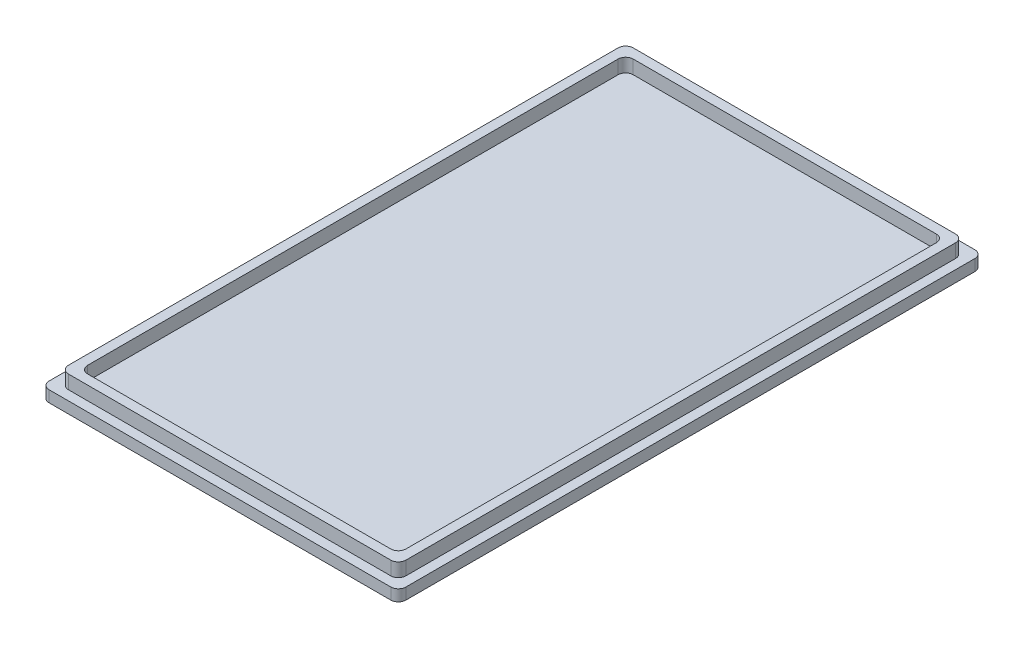
from build123d import *

# Parameters (mm, degrees)
SKETCH1_W           = 47.09116882
SKETCH1_H           = 77.09116882
BOSS_EXTRUDE1_DEPTH = 1.5
SKETCH2_W           = 44.545584412
SKETCH2_H           = 74.545584412
SKETCH2_W_2         = 42
SKETCH2_H_2         = 72
BOSS_EXTRUDE2_DEPTH = 1.8
FILLET1_R           = 1
SKETCH3_W           = 24
SKETCH3_H           = 64
BOSS_EXTRUDE3_DEPTH = 10
SKETCH4_W           = 48
SKETCH4_H           = 6
CUT_EXTRUDE1_DEPTH  = 24
FILLET2_R           = 6
FILLET3_R           = 1


with BuildPart() as part:
    # Sketch1 → Boss-Extrude1 (new body)
    with BuildSketch(Plane(origin=(0, 0, 0), x_dir=(1, 0, 0), z_dir=(0, 1, 0))):
        with Locations((23.54558441, -38.54558441)):
            Rectangle(SKETCH1_W, SKETCH1_H)
    extrude(amount=BOSS_EXTRUDE1_DEPTH)

    # Sketch2 → Boss-Extrude2 (add)
    with BuildSketch(Plane(origin=(0, 1.5, 0), x_dir=(1, 0, 0), z_dir=(0, 1, 0))):
        with Locations((23.545584412, -38.545584412)):
            Rectangle(SKETCH2_W, SKETCH2_H)
        with Locations((23.545584412, -38.545584412)):
            Rectangle(SKETCH2_W_2, SKETCH2_H_2, mode=Mode.SUBTRACT)
    extrude(amount=BOSS_EXTRUDE2_DEPTH)

    # Fillet1
    fillet1_edges = [part.edges().sort_by_distance(p)[0] for p in [
        (1.272792206, 2.4, 1.272792206),
        (1.272792206, 2.4, 75.818376618),
        (45.818376618, 2.4, 75.818376618),
        (45.818376618, 2.4, 1.272792206),
        (44.545584412, 2.4, 74.545584412),
        (44.545584412, 2.4, 2.545584412),
        (2.545584412, 2.4, 2.545584412),
        (2.545584412, 2.4, 74.545584412),
        (0, 0.75, 0),
        (47.09116882, 0.75, 0),
        (47.09116882, 0.75, 77.09116882),
        (0, 0.75, 77.09116882),
    ]]
    fillet(fillet1_edges, radius=FILLET1_R)

    # Sketch3 → Boss-Extrude3 (add)
    with BuildSketch(Plane.XZ):
        with Locations((23.54558441, 38.542813716)):
            Rectangle(SKETCH3_W, SKETCH3_H)
    extrude(amount=BOSS_EXTRUDE3_DEPTH)

    # Sketch4 → Cut-Extrude1 (cut)
    with BuildSketch(Plane.ZY.offset(-11.54558441)):
        with Locations((38.542813716, -3)):
            Rectangle(SKETCH4_W, SKETCH4_H)
    extrude(amount=-CUT_EXTRUDE1_DEPTH, mode=Mode.SUBTRACT)

    # Fillet2
    fillet2_edges = [part.edges().sort_by_distance(p)[0] for p in [
        (23.54558441, -10, 70.542813716),
        (23.54558441, -10, 6.542813716),
    ]]
    fillet(fillet2_edges, radius=FILLET2_R)

    # Fillet3
    fillet3_edges = [part.edges().sort_by_distance(p)[0] for p in [
        (23.54558441, -6, 14.542813716),
        (23.54558441, -6, 62.542813716),
    ]]
    fillet(fillet3_edges, radius=FILLET3_R)


solid = part.part
